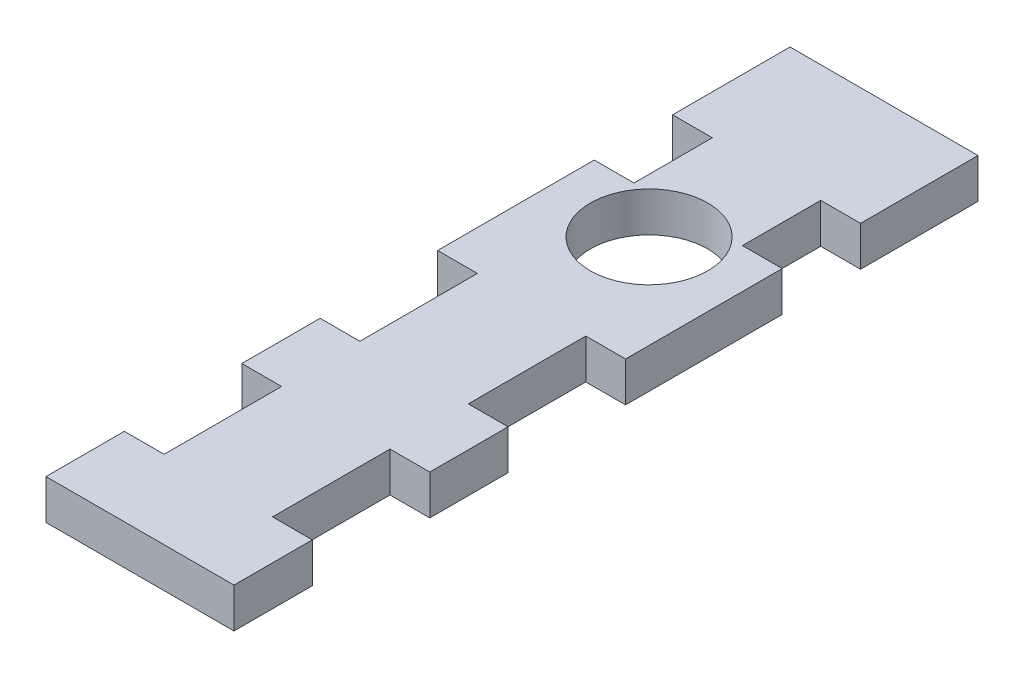
from build123d import *

# Parameters (mm, degrees)
SKETCH1_R           = 7.5
BOSS_EXTRUDE1_DEPTH = 5.08
SKETCH2_W           = 5.08
SKETCH2_H           = 10
SKETCH2_H_2         = 15
CUT_EXTRUDE1_DEPTH  = 5.08


with BuildPart() as part:
    # Sketch1 → Boss-Extrude1 (new body)
    with BuildSketch(Plane(origin=(0, 0, 0), x_dir=(1, 0, 0), z_dir=(0, 1, 0))):
        Polygon((12, -32.5), (-12, -32.5), (-12, 32.5), (-12, 62.5), (12, 62.5), (12, 32.5), align=None)
        with Locations((0, 32.5)):
            Circle(SKETCH1_R, mode=Mode.SUBTRACT)
    extrude(amount=BOSS_EXTRUDE1_DEPTH)

    # Sketch2 → Cut-Extrude1 (cut)
    with BuildSketch(Plane(origin=(0, 5.08, 0), x_dir=(1, 0, 0), z_dir=(0, 1, 0))):
        with Locations((-9.46, 42.5)):
            Rectangle(SKETCH2_W, SKETCH2_H)
        with Locations((-9.46, -15)):
            Rectangle(SKETCH2_W, SKETCH2_H_2)
        with Locations((-9.46, 10)):
            Rectangle(SKETCH2_W, SKETCH2_H_2)
    cut_extrude1 = extrude(amount=-CUT_EXTRUDE1_DEPTH, mode=Mode.SUBTRACT)

    # Mirror2: Cut-Extrude1 across plane
    add(cut_extrude1.mirror(Plane(origin=(0, 0, 0), x_dir=(0, 0, 1), z_dir=(1, 0, 0))), mode=Mode.SUBTRACT)


solid = part.part
